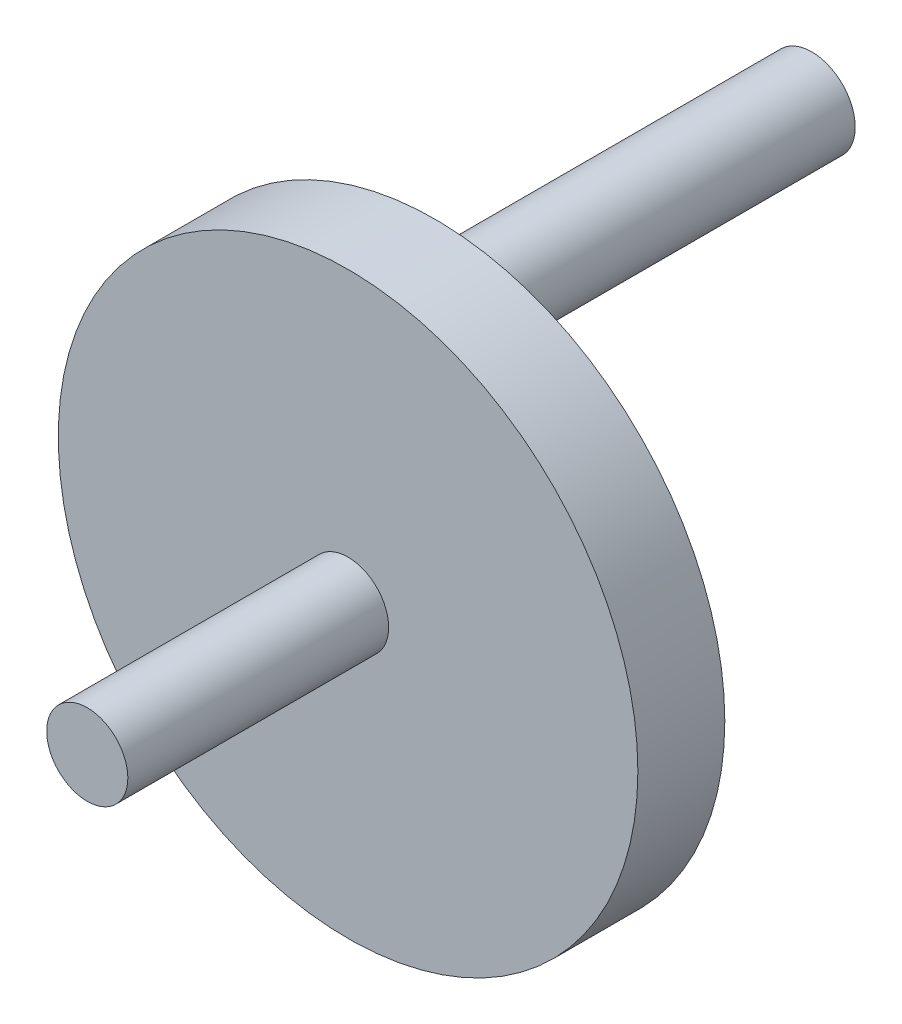
from build123d import *

# Parameters (mm, degrees)
SKETCH1_R           = 50
SKETCH1_R_2         = 7.5
BOSS_EXTRUDE1_DEPTH = 15
SKETCH2_R           = 7.5
BOSS_EXTRUDE2_DEPTH = 80
SKETCH5_R           = 7
BOSS_EXTRUDE3_DEPTH = 45


with BuildPart() as part:
    # Sketch1 → Boss-Extrude1 (new body)
    with BuildSketch(Plane.XY):
        Circle(SKETCH1_R)
        with Locations((0, 35)):
            Circle(SKETCH1_R_2, mode=Mode.SUBTRACT)
    extrude(amount=BOSS_EXTRUDE1_DEPTH)

    # Sketch2 → Boss-Extrude2 (add)
    with BuildSketch(Plane.XY.offset(15)):
        with Locations((0, 35)):
            Circle(SKETCH2_R)
    extrude(amount=-BOSS_EXTRUDE2_DEPTH)

    # Sketch5 → Boss-Extrude3 (add)
    with BuildSketch(Plane.XY.offset(15)):
        Circle(SKETCH5_R)
    extrude(amount=BOSS_EXTRUDE3_DEPTH)


solid = part.part
